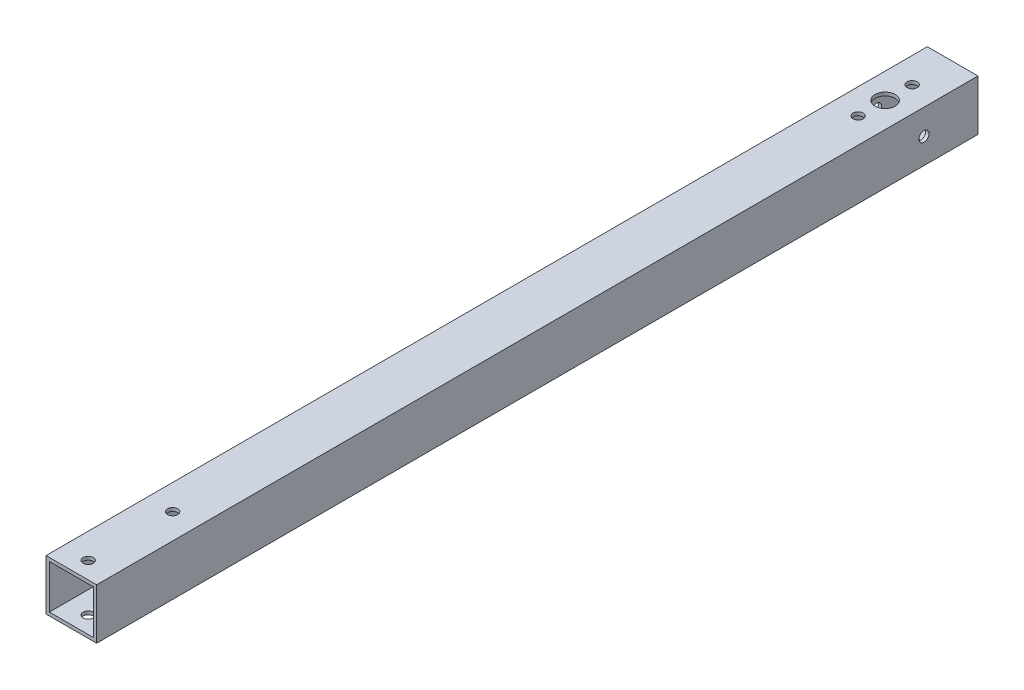
from build123d import *

# Parameters (mm, degrees)
SKETCH1_W                    = 15
SKETCH1_H                    = 15
BOSS_EXTRUDE1_DEPTH          = 261
SKETCH2_W                    = 13
SKETCH2_H                    = 13
CUT_EXTRUDE1_DEPTH           = 261
F_3_0_3_DIAMETER_HOLE1_D     = 3
F_3_0_3_DIAMETER_HOLE2_D     = 3
F_6_0_6_DIAMETER_HOLE1_D     = 6
F_6_0_6_DIAMETER_HOLE1_DEPTH = 10
F_6_0_6_DIAMETER_HOLE1_TIP   = 1.802581857
F_3_0_3_DIAMETER_HOLE3_D     = 3


with BuildPart() as part:
    # Sketch1 → Boss-Extrude1 (new body)
    with BuildSketch(Plane.XY):
        with Locations((-36.796141786, 14.648070893)):
            Rectangle(SKETCH1_W, SKETCH1_H)
    extrude(amount=BOSS_EXTRUDE1_DEPTH)

    # Sketch2 → Cut-Extrude1 (cut)
    with BuildSketch(Plane(origin=(0, 0, 0), x_dir=(-1, 0, 0), z_dir=(0, 0, -1))):
        with Locations((36.796141786, 14.648070893)):
            Rectangle(SKETCH2_W, SKETCH2_H)
    extrude(amount=-CUT_EXTRUDE1_DEPTH, mode=Mode.SUBTRACT)

    # Ø3.0 (3) Diameter Hole1 (through all)
    with Locations(Plane(origin=(0, 22.148070893, 0), x_dir=(1, 0, 0), z_dir=(0, 1, 0))):
        with Locations((-36.796141786, -256), (-36.796141786, -231)):
            Hole(F_3_0_3_DIAMETER_HOLE1_D / 2)

    # Ø3.0 (3) Diameter Hole2 (through all)
    with Locations(Plane(origin=(0, 22.148070893, 0), x_dir=(1, 0, 0), z_dir=(0, 1, 0))):
        with Locations((-36.796141786, -12), (-36.796141786, -28)):
            Hole(F_3_0_3_DIAMETER_HOLE2_D / 2)

    # Ø6.0 (6) Diameter Hole1
    with Locations(Plane(origin=(0, 22.148070893, 0), x_dir=(1, 0, 0), z_dir=(0, 1, 0))):
        with Locations((-36.796141786, -20)):
            Hole(F_6_0_6_DIAMETER_HOLE1_D / 2, depth=F_6_0_6_DIAMETER_HOLE1_DEPTH)
            with Locations((0, 0, -(F_6_0_6_DIAMETER_HOLE1_DEPTH + F_6_0_6_DIAMETER_HOLE1_TIP / 2))):  # 118° drill point
                Cone(0, F_6_0_6_DIAMETER_HOLE1_D / 2, F_6_0_6_DIAMETER_HOLE1_TIP, mode=Mode.SUBTRACT)

    # Ø3.0 (3) Diameter Hole3 (through all)
    with Locations(Plane.ZY.offset(44.296141786)):
        with Locations((16, 14.648070893)):
            Hole(F_3_0_3_DIAMETER_HOLE3_D / 2)


solid = part.part
